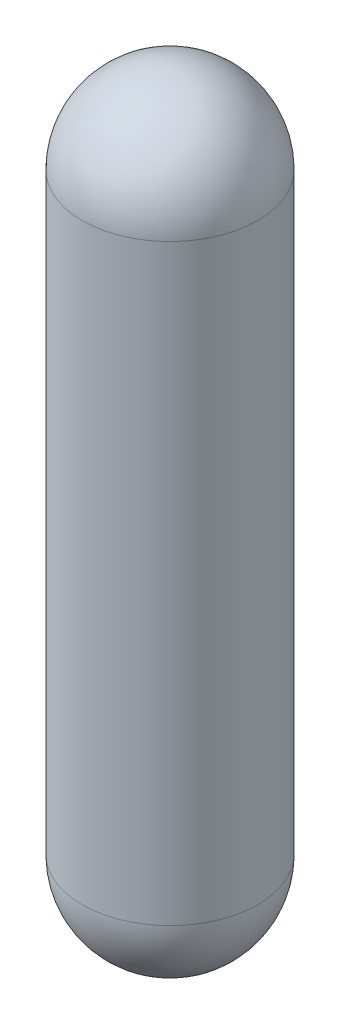
from build123d import *


with BuildPart() as part:
    # Sketch1 → Revolve1 (revolve)
    with BuildSketch(Plane.XY):
        with BuildLine():
            Line((0, 1768.86), (0, 1771.4))
            ThreePointArc((0, 1771.4), (161.644610179, 1704.444610179), (228.6, 1542.8))
            Line((228.6, 1542.8), (228.6, 0))
            ThreePointArc((228.6, 0), (161.644610179, -161.644610179), (0, -228.6))
            Line((0, -228.6), (0, -226.06))
            ThreePointArc((0, -226.06), (152.913929779, -156.149448595), (215.263788015, 0))
            Line((215.263788015, 0), (215.263788015, 1542.8))
            ThreePointArc((215.263788015, 1542.8), (152.913929779, 1698.949448595), (0, 1768.86))
        make_face()
    revolve(axis=Axis((0, 0, 0), (0, 1, 0)))


solid = part.part
